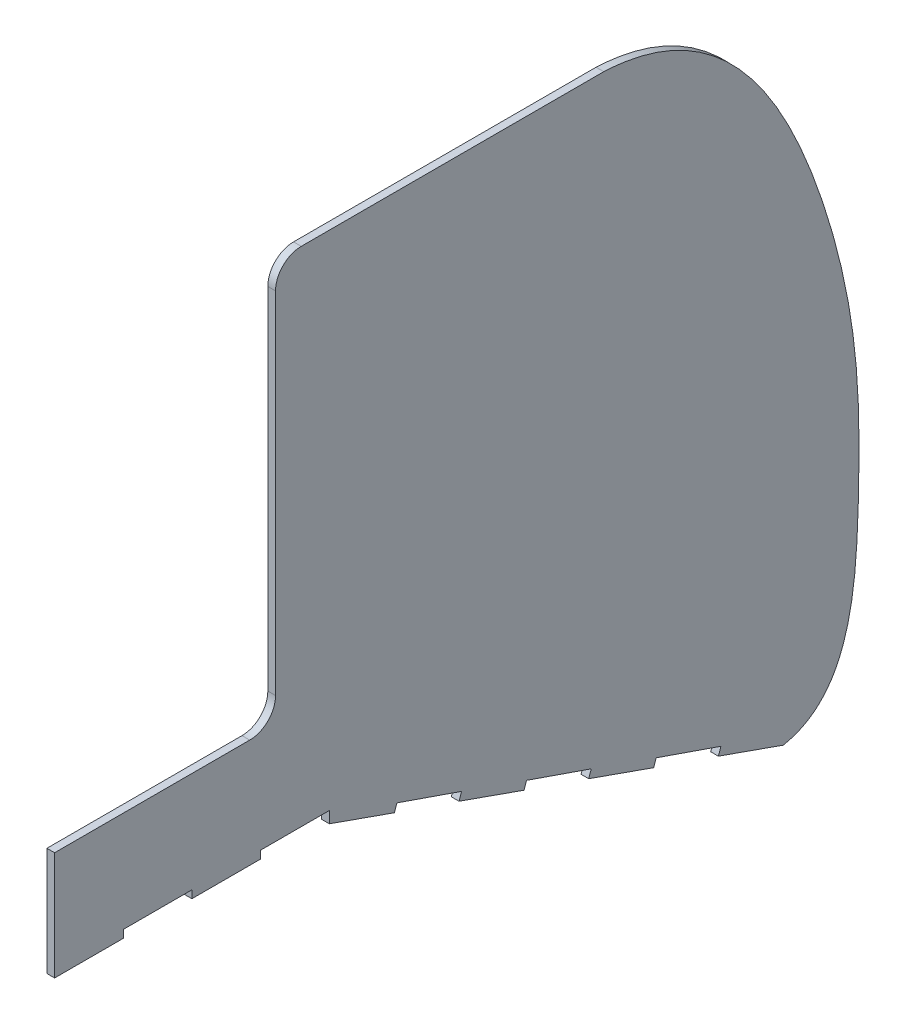
from build123d import *

# Parameters (mm, degrees)
BOSS_EXTRUDE1_DEPTH = 3


with BuildPart() as part:
    # Sketch1 → Boss-Extrude1 (new body)
    with BuildSketch(Plane(origin=(0, 0, 0), x_dir=(0, 0, -1), z_dir=(1, 0, 0))):
        with BuildLine():
            Line((-127.67328154, 50.621631606), (-127.67328154, 186.921746015))
            ThreePointArc((-127.67328154, 186.921746015), (-124.744349352, 193.992813827), (-117.67328154, 196.921746015))
            Line((-117.67328154, 196.921746015), (0, 196.921746015))
            add(Edge.make_bspline(
                [(0, 196.921746015), (46.196792572, 194.855720742), (79.88487553, 137.404046632), (99.182170179, 59.208836991), (100.052993092, 0.303625018), (95.624976693, -59.91038793), (69.844770806, -64.869245027)],
                knots=[0, 0, 0, 0, 0.394606227, 0.564234061, 0.764368842, 1, 1, 1, 1], degree=3))
            Line((69.844770806, -64.869245027), (44.576317349, -55.949963479))
            Line((44.576317349, -55.949963479), (45.557040507, -53.114794685))
            Line((45.557040507, -53.114794685), (20.392883459, -44.410173069))
            Line((20.392883459, -44.410173069), (19.412160301, -47.245341862))
            Line((19.412160301, -47.245341862), (-5.856293156, -38.326060314))
            Line((-5.856293156, -38.326060314), (-4.875569998, -35.490891521))
            Line((-4.875569998, -35.490891521), (-30.039727046, -26.786269904))
            Line((-30.039727046, -26.786269904), (-31.020450204, -29.621438697))
            Line((-31.020450204, -29.621438697), (-56.28890366, -20.702157149))
            Line((-56.28890366, -20.702157149), (-55.308180502, -17.866988356))
            Line((-55.308180502, -17.866988356), (-80.47233755, -9.162366739))
            Line((-80.47233755, -9.162366739), (-81.453060708, -11.997535533))
            Line((-81.453060708, -11.997535533), (-106.721514165, -3.078253985))
            Line((-106.721514165, -3.078253985), (-106.721514165, 1.421746015))
            Line((-106.721514165, 1.421746015), (-133.5, 1.421746015))
            Line((-133.5, 1.421746015), (-133.5, -1.578253985))
            Line((-133.5, -1.578253985), (-160.2, -1.578253985))
            Line((-160.2, -1.578253985), (-160.2, 1.421746015))
            Line((-160.2, 1.421746015), (-186.9, 1.421746015))
            Line((-186.9, 1.421746015), (-186.9, -1.578253985))
            Line((-186.9, -1.578253985), (-213.6, -1.578253985))
            Line((-213.6, -1.578253985), (-213.6, 40.621746015))
            Line((-213.6, 40.621746015), (-137.721116386, 40.621746015))
            ThreePointArc((-137.721116386, 40.621746015), (-130.619146174, 43.533671799), (-127.67328154, 50.621631606))
        make_face()
    extrude(amount=BOSS_EXTRUDE1_DEPTH)


solid = part.part
